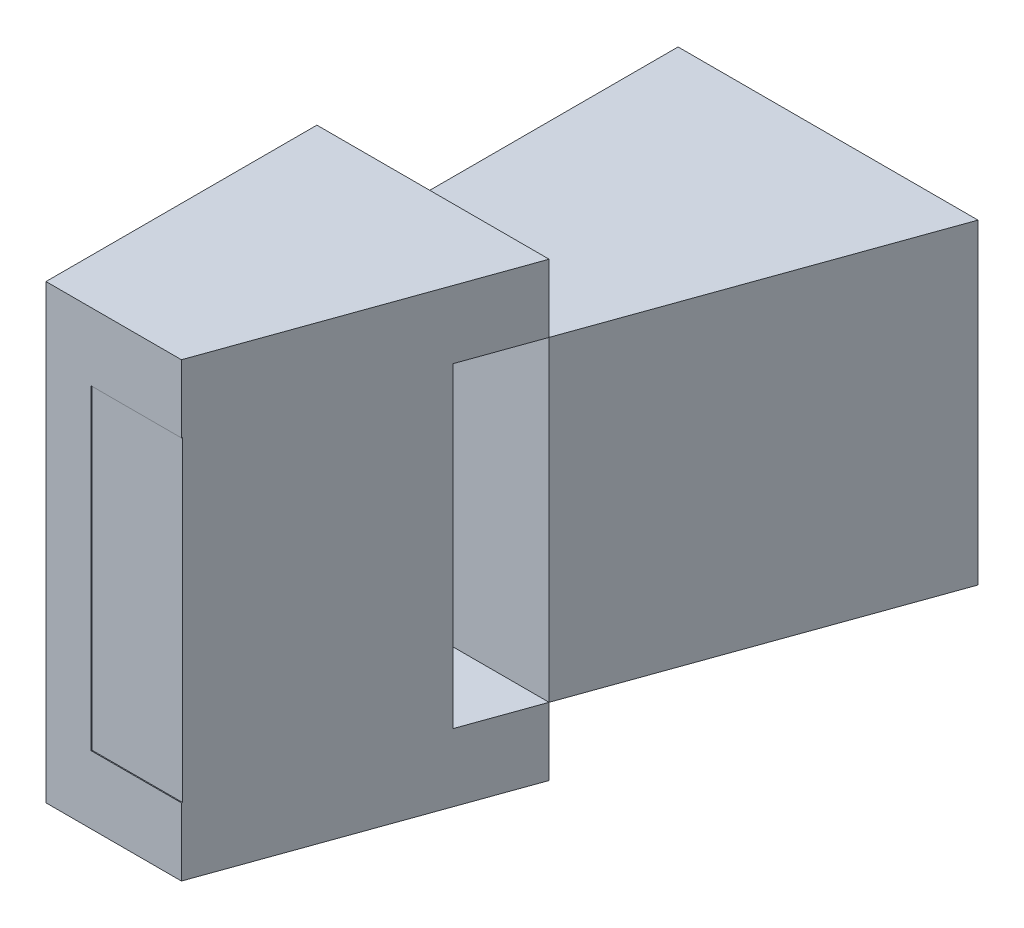
from build123d import *

# Parameters (mm, degrees)
ESBO_O1_W                  = 60
ESBO_O1_H                  = 100
RESSALTO_EXTRUS_O1_DEPTH   = 10
ESBO_O2_W                  = 60
ESBO_O2_H                  = 15
RESSALTO_EXTRUS_O2_DEPTH   = 70
RESSALTO_EXTRUS_O2_2_DEPTH = 70
CORTE_EXTRUS_O3_DEPTH      = 121
RESSALTO_EXTRUS_O4_DEPTH   = 70
RESSALTO_EXTRUS_O5_DEPTH   = 70


with BuildPart() as part:
    # Esboço1 → Ressalto-extrusão1 (new body)
    with BuildSketch(Plane(origin=(0, 0, 0), x_dir=(0, 0, -1), z_dir=(1, 0, 0))):
        with Locations((-11.609907121, -21.021671827)):
            Rectangle(ESBO_O1_W, ESBO_O1_H)
    extrude(amount=RESSALTO_EXTRUS_O1_DEPTH)



with BuildPart() as body_2:
    # Esboço2 → Ressalto-extrusão2 (new body)
    with BuildSketch(Plane(origin=(10, 0, 0), x_dir=(0, 0, -1), z_dir=(1, 0, 0))):
        with Locations((-11.609907121, 21.478328173)):
            Rectangle(ESBO_O2_W, ESBO_O2_H)
    extrude(amount=RESSALTO_EXTRUS_O2_DEPTH)


with BuildPart() as body_3:
    # Esboço2 → Ressalto-extrus_o2 2 (new body)
    with BuildSketch(Plane(origin=(10, 0, 0), x_dir=(0, 0, -1), z_dir=(1, 0, 0))):
        with Locations((-11.609907121, -63.521671827)):
            Rectangle(ESBO_O2_W, ESBO_O2_H)
    extrude(amount=RESSALTO_EXTRUS_O2_2_DEPTH)


with BuildPart() as corte_extrus_o3_tool:
    # Esboço3 → Corte-extrusão3 (new body)
    with BuildSketch(Plane.XZ.offset(71.021671827)):
        Polygon((30, 41.609907121), (80, 41.609907121), (80, -98.390092879), align=None)
    extrude(amount=-CORTE_EXTRUS_O3_DEPTH)


with BuildPart() as body_2_1:
    add(body_2.part)

    # Corte-extrusão3: cut by corte_extrus_o3_tool
    add(corte_extrus_o3_tool.part, mode=Mode.SUBTRACT)


with BuildPart() as body_3_1:
    add(body_3.part)

    # Corte-extrusão3: cut by corte_extrus_o3_tool
    add(corte_extrus_o3_tool.part, mode=Mode.SUBTRACT)


with BuildPart() as part_1:
    add(part.part)

    add(body_2_1.part)  # Ressalto-extrusão4 merges body 2

    add(body_3_1.part)  # Ressalto-extrusão4 merges body 3
    # Esboço7 → Ressalto-extrusão4 (add)
    with BuildSketch(Plane.XZ.offset(-13.978328173)):
        Polygon((30.072142547, 41.407907988), (10, 41.407907988), (10, -2.717102769), (40, -2.717102769), (45.831074961, -2.717102769), align=None)
    extrude(amount=RESSALTO_EXTRUS_O4_DEPTH)


with BuildPart() as body_2_2:
    # Esboço9 → Ressalto-extrusão5 (new body)
    with BuildSketch(Plane.XZ.offset(-13.978328173)):
        Polygon((51.428571429, -18.390092879), (76.428571429, -88.390092879), (10, -88.390092879), (10, -18.390092879), align=None)
    extrude(amount=RESSALTO_EXTRUS_O5_DEPTH)


solid = Compound([part_1.part, body_2_2.part])
